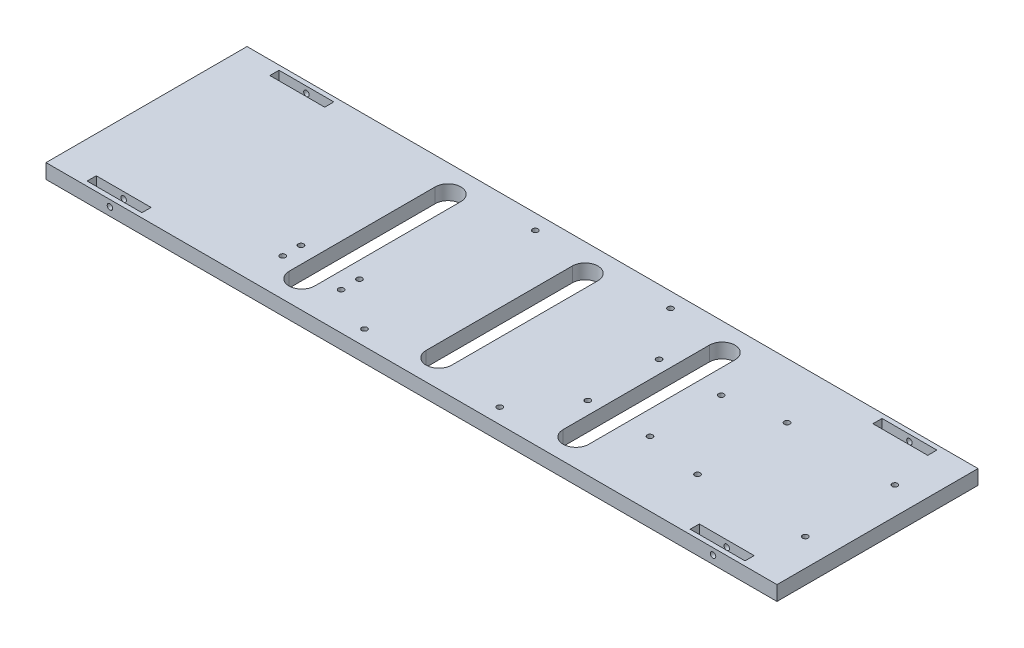
from build123d import *

# Parameters (mm, degrees)
SKETCH_1_W          = 400
SKETCH_1_H          = 110
EXTRUDE_1_DEPTH     = 8
SKETCH_2_W          = 15
SKETCH_2_H          = 2.5
CUT_EXTRUDE_1_DEPTH = 7
CUT_EXTRUDE_2_DEPTH = 9
SKETCH_8_R          = 1.5
CUT_EXTRUDE_4_DEPTH = 111
SKETCH_11_R         = 1.5
CUT_EXTRUDE_6_DEPTH = 10
SKETCH_12_R         = 1.5
CUT_EXTRUDE_7_DEPTH = 10
SKETCH_13_R         = 1.5
CUT_EXTRUDE_8_DEPTH = 10
SKETCH_14_R         = 1.5
CUT_EXTRUDE_9_DEPTH = 9


with BuildPart() as part:
    # 草图1 → 凸台-拉伸1 (new body)
    with BuildSketch(Plane(origin=(0, 0, 0), x_dir=(1, 0, 0), z_dir=(0, 1, 0))):
        Rectangle(SKETCH_1_W, SKETCH_1_H)
    extrude(amount=EXTRUDE_1_DEPTH)

    # 草图2 → 切除-拉伸1 (cut)
    with BuildSketch(Plane(origin=(0, 8, 0), x_dir=(1, 0, 0), z_dir=(0, 1, 0))):
        with Locations((-172.5, 51.25)):
            Rectangle(SKETCH_2_W, SKETCH_2_H)
        with Locations((-157.5, 51.25)):
            Rectangle(SKETCH_2_W, SKETCH_2_H)
        with Locations((-157.5, 48.75)):
            Rectangle(SKETCH_2_W, SKETCH_2_H)
        with Locations((-172.5, 48.75)):
            Rectangle(SKETCH_2_W, SKETCH_2_H)
        with Locations((-172.5, -48.75)):
            Rectangle(SKETCH_2_W, SKETCH_2_H)
        with Locations((-172.5, -51.25)):
            Rectangle(SKETCH_2_W, SKETCH_2_H)
        with Locations((-157.5, -51.25)):
            Rectangle(SKETCH_2_W, SKETCH_2_H)
        with Locations((-157.5, -48.75)):
            Rectangle(SKETCH_2_W, SKETCH_2_H)
        with Locations((172.5, 51.25)):
            Rectangle(SKETCH_2_W, SKETCH_2_H)
        with Locations((157.5, 51.25)):
            Rectangle(SKETCH_2_W, SKETCH_2_H)
        with Locations((157.5, 48.75)):
            Rectangle(SKETCH_2_W, SKETCH_2_H)
        with Locations((172.5, 48.75)):
            Rectangle(SKETCH_2_W, SKETCH_2_H)
        with Locations((157.5, -48.75)):
            Rectangle(SKETCH_2_W, SKETCH_2_H)
        with Locations((157.5, -51.25)):
            Rectangle(SKETCH_2_W, SKETCH_2_H)
        with Locations((172.5, -51.25)):
            Rectangle(SKETCH_2_W, SKETCH_2_H)
        with Locations((172.5, -48.75)):
            Rectangle(SKETCH_2_W, SKETCH_2_H)
    extrude(amount=-CUT_EXTRUDE_1_DEPTH, mode=Mode.SUBTRACT)

    # 草图3 → 切除-拉伸2 (cut, through all)
    with BuildSketch(Plane(origin=(0, 8, 0), x_dir=(1, 0, 0), z_dir=(0, 1, 0))):
        with BuildLine():
            Line((-82, 40), (-82, 0))
            Line((-82, 0), (-75, 0))
            Line((-75, 0), (-75, 47))
            ThreePointArc((-75, 47), (-79.949747468, 44.949747468), (-82, 40))
        make_face()
        with BuildLine():
            Line((-75, 47), (-75, 0))
            Line((-75, 0), (-68, 0))
            Line((-68, 0), (-68, 40))
            ThreePointArc((-68, 40), (-70.050252532, 44.949747468), (-75, 47))
        make_face()
        with BuildLine():
            Line((-75, 0), (-82, 0))
            Line((-82, 0), (-82, -40))
            ThreePointArc((-82, -40), (-79.949747468, -44.949747468), (-75, -47))
            Line((-75, -47), (-75, 0))
        make_face()
        with BuildLine():
            Line((-68, 0), (-75, 0))
            Line((-75, 0), (-75, -47))
            ThreePointArc((-75, -47), (-70.050252532, -44.949747468), (-68, -40))
            Line((-68, -40), (-68, 0))
        make_face()
        with BuildLine():
            Line((-7, 40), (-7, 0))
            Line((-7, 0), (0, 0))
            Line((0, 0), (0, 47))
            ThreePointArc((0, 47), (-4.949747468, 44.949747468), (-7, 40))
        make_face()
        with BuildLine():
            Line((0, 47), (0, 0))
            Line((0, 0), (7, 0))
            Line((7, 0), (7, 40))
            ThreePointArc((7, 40), (4.949747468, 44.949747468), (0, 47))
        make_face()
        with BuildLine():
            Line((0, 0), (-7, 0))
            Line((-7, 0), (-7, -40))
            ThreePointArc((-7, -40), (-4.949747468, -44.949747468), (0, -47))
            Line((0, -47), (0, 0))
        make_face()
        with BuildLine():
            Line((7, 0), (0, 0))
            Line((0, 0), (0, -47))
            ThreePointArc((0, -47), (4.949747468, -44.949747468), (7, -40))
            Line((7, -40), (7, 0))
        make_face()
        with BuildLine():
            Line((68, 40), (68, 0))
            Line((68, 0), (75, 0))
            Line((75, 0), (75, 47))
            ThreePointArc((75, 47), (70.050252532, 44.949747468), (68, 40))
        make_face()
        with BuildLine():
            Line((75, 47), (75, 0))
            Line((75, 0), (82, 0))
            Line((82, 0), (82, 40))
            ThreePointArc((82, 40), (79.949747468, 44.949747468), (75, 47))
        make_face()
        with BuildLine():
            Line((75, 0), (68, 0))
            Line((68, 0), (68, -40))
            ThreePointArc((68, -40), (70.050252532, -44.949747468), (75, -47))
            Line((75, -47), (75, 0))
        make_face()
        with BuildLine():
            Line((82, 0), (75, 0))
            Line((75, 0), (75, -47))
            ThreePointArc((75, -47), (79.949747468, -44.949747468), (82, -40))
            Line((82, -40), (82, 0))
        make_face()
    extrude(amount=-CUT_EXTRUDE_2_DEPTH, mode=Mode.SUBTRACT)

    # 草图8 → 切除-拉伸4 (cut, through all)
    with BuildSketch(Plane.XY.offset(55)):
        with Locations((165, 4.5)):
            Circle(SKETCH_8_R)
        with Locations((-165, 4.5)):
            Circle(SKETCH_8_R)
    extrude(amount=-CUT_EXTRUDE_4_DEPTH, mode=Mode.SUBTRACT)

    # 草图11 → 切除-拉伸6 (cut)
    with BuildSketch(Plane(origin=(0, 8, 0), x_dir=(1, 0, 0), z_dir=(0, 1, 0))):
        with Locations((126, 24.5)):
            Circle(SKETCH_11_R)
        with Locations((185, 24.5)):
            Circle(SKETCH_11_R)
        with Locations((185, -24.5)):
            Circle(SKETCH_11_R)
        with Locations((126, -24.5)):
            Circle(SKETCH_11_R)
    extrude(amount=-CUT_EXTRUDE_6_DEPTH, mode=Mode.SUBTRACT)

    # 草图12 → 切除-拉伸7 (cut)
    with BuildSketch(Plane(origin=(0, 8, 0), x_dir=(1, 0, 0), z_dir=(0, 1, 0))):
        with Locations((61, 19.5)):
            Circle(SKETCH_12_R)
        with Locations((95, 19.5)):
            Circle(SKETCH_12_R)
        with Locations((95, -19.5)):
            Circle(SKETCH_12_R)
        with Locations((61, -19.5)):
            Circle(SKETCH_12_R)
    extrude(amount=-CUT_EXTRUDE_7_DEPTH, mode=Mode.SUBTRACT)

    # 草图13 → 切除-拉伸8 (cut)
    with BuildSketch(Plane(origin=(0, 8, 0), x_dir=(1, 0, 0), z_dir=(0, 1, 0))):
        with Locations((-34, 46.75)):
            Circle(SKETCH_13_R)
        with Locations((40, 46.75)):
            Circle(SKETCH_13_R)
        with Locations((40, -46.75)):
            Circle(SKETCH_13_R)
        with Locations((-34, -46.75)):
            Circle(SKETCH_13_R)
    extrude(amount=-CUT_EXTRUDE_8_DEPTH, mode=Mode.SUBTRACT)

    # 草图14 → 切除-拉伸9 (cut, through all)
    with BuildSketch(Plane(origin=(0, 8, 0), x_dir=(1, 0, 0), z_dir=(0, 1, 0))):
        with Locations((-91, -24.5)):
            Circle(SKETCH_14_R)
        with Locations((-91, -34.5)):
            Circle(SKETCH_14_R)
        with Locations((-59, -34.5)):
            Circle(SKETCH_14_R)
        with Locations((-59, -24.5)):
            Circle(SKETCH_14_R)
    extrude(amount=-CUT_EXTRUDE_9_DEPTH, mode=Mode.SUBTRACT)


solid = part.part
